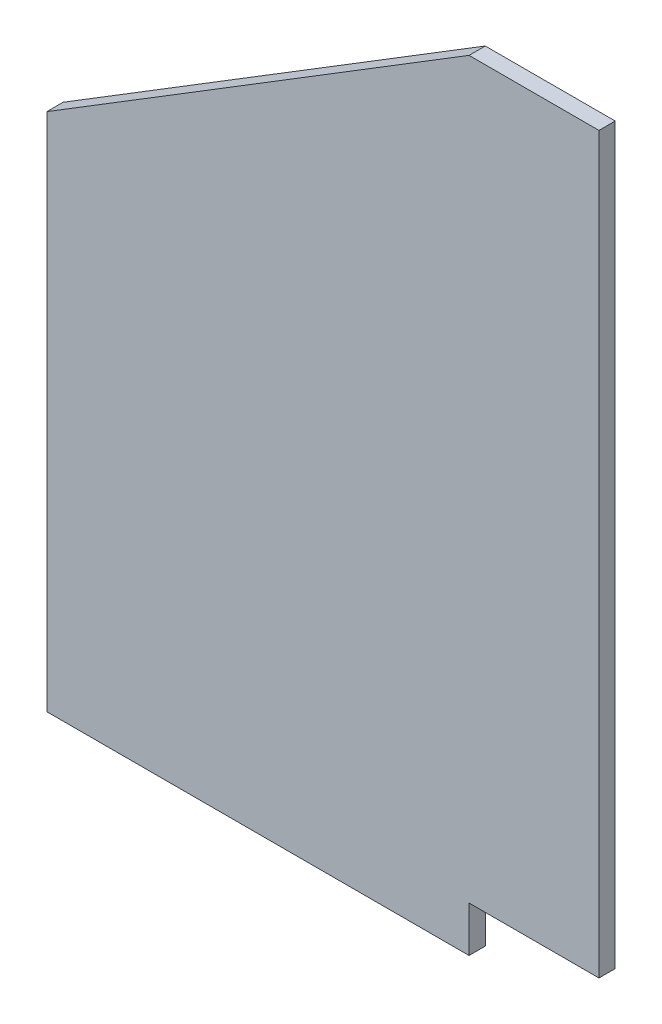
from build123d import *

# Parameters (mm, degrees)
BOSS_EXTRUDE1_DEPTH = 3.175


with BuildPart() as part:
    # Sketch1 → Boss-Extrude1 (new body)
    with BuildSketch(Plane.XY):
        Polygon((0, 0), (0, 143.51), (-25.4, 143.51), (-107.95, 92.71), (-107.95, -8.89), (-25.4, -8.89), (-25.4, 0), align=None)
    extrude(amount=BOSS_EXTRUDE1_DEPTH)


solid = part.part
